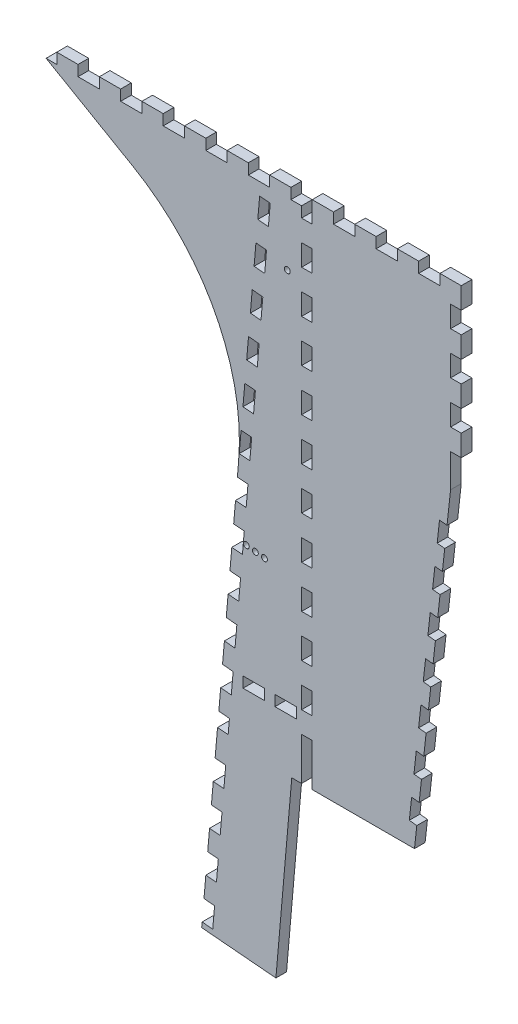
from build123d import *

# Parameters (mm, degrees)
SKETCH1_R           = 1.75
BOSS_EXTRUDE1_DEPTH = 6.35
CUT_EXTRUDE1_DEPTH  = 7.35
SKETCH5_W           = 12.7
SKETCH5_H           = 6.35
CUT_EXTRUDE3_DEPTH  = 7.35
FILLET1_R           = 127
LPATTERN1_COUNT     = 10
LPATTERN1_PITCH     = 25.4
SKETCH6_W           = 6.35
SKETCH6_H           = 12.7
CUT_EXTRUDE4_DEPTH  = 7.35
CUT_EXTRUDE5_DEPTH  = 7.35
LPATTERN3_COUNT     = 7
LPATTERN3_PITCH     = 25.4
SKETCH10_W          = 6.35
SKETCH10_H          = 83.214016323
BOSS_EXTRUDE2_DEPTH = 6.35
LPATTERN4_COUNT     = 4
LPATTERN4_PITCH     = 25.4
SKETCH11_W          = 6.35
SKETCH11_H          = 7.014016323
CUT_EXTRUDE7_DEPTH  = 7.35
SKETCH12_W          = 6.35
SKETCH12_H          = 12.7
CUT_EXTRUDE8_DEPTH  = 7.35
LPATTERN5_COUNT     = 12
LPATTERN5_PITCH     = 25.4
CUT_EXTRUDE9_DEPTH  = 7.35
LPATTERN6_COUNT     = 12
LPATTERN6_PITCH     = 25.4
SKETCH15_W          = 12.7
SKETCH15_H          = 6.35
CUT_EXTRUDE10_DEPTH = 7.35
SKETCH16_W          = 6.35
SKETCH16_H          = 12.7
CUT_EXTRUDE11_DEPTH = 7.35
BOSS_EXTRUDE4_DEPTH = 6.35
LPATTERN7_COUNT     = 5
LPATTERN7_PITCH     = 25.4


with BuildPart() as part:
    # Sketch1 → Boss-Extrude1 (new body)
    with BuildSketch(Plane.XY):
        Polygon((-101.927346492, 304.8), (-101.927346492, 298.45), (19.954542011, 228.081458863), (0, 0), (145.722653508, 0), (145.722653508, 304.8), align=None)
        with Locations((17.516544975, 106.665925891)):
            Circle(SKETCH1_R, mode=Mode.SUBTRACT)
        with Locations((22.915962626, 105.907087227)):
            Circle(SKETCH1_R, mode=Mode.SUBTRACT)
        with Locations((28.338574185, 105.337147786)):
            Circle(SKETCH1_R, mode=Mode.SUBTRACT)
        with Locations((41.953172759, 260.952721575)):
            Circle(SKETCH1_R, mode=Mode.SUBTRACT)
    extrude(amount=BOSS_EXTRUDE1_DEPTH)

    # Sketch2 → Cut-Extrude1 (cut, through all)
    with BuildSketch(Plane.XY.offset(6.35)):
        Polygon((145.722653508, 254), (117.824574416, 0), (145.722653508, 0), align=None)
    extrude(amount=-CUT_EXTRUDE1_DEPTH, mode=Mode.SUBTRACT)

    # Sketch5 → Cut-Extrude3 (cut, through all)
    with BuildSketch(Plane.XY.offset(6.35)):
        with Locations((126.672653508, 301.625)):
            Rectangle(SKETCH5_W, SKETCH5_H)
    cut_extrude3 = extrude(amount=-CUT_EXTRUDE3_DEPTH, mode=Mode.SUBTRACT)

    # Fillet1
    fillet1_edges = [part.edges().sort_by_distance(p)[0] for p in [
        (19.954542011, 228.081458863, 3.175),
    ]]
    fillet(fillet1_edges, radius=FILLET1_R)

    # LPattern1: Cut-Extrude3 ×10
    with Locations(*[(-i * LPATTERN1_PITCH, 0, 0) for i in range(1, LPATTERN1_COUNT)]):
        add(cut_extrude3, mode=Mode.SUBTRACT)

    # Sketch6 → Cut-Extrude4 (cut, through all)
    with BuildSketch(Plane.XY.offset(6.35)):
        with Locations((142.547653508, 285.75)):
            Rectangle(SKETCH6_W, SKETCH6_H)
    cut_extrude4 = extrude(amount=-CUT_EXTRUDE4_DEPTH, mode=Mode.SUBTRACT)

    # Sketch8 → Cut-Extrude5 (cut, through all)
    with BuildSketch(Plane.XY.offset(6.35)):
        Polygon((119.211139876, 12.624081599), (120.597705336, 25.248163198), (116.121058229, 25.739855541), (114.734492769, 13.115773942), align=None)
    cut_extrude5 = extrude(amount=-CUT_EXTRUDE5_DEPTH, mode=Mode.SUBTRACT)

    # LPattern3: Cut-Extrude5 ×7
    with Locations(*[Vector(0.109178383, 0.994022173, 0) * (i * LPATTERN3_PITCH) for i in range(1, LPATTERN3_COUNT)]):
        add(cut_extrude5, mode=Mode.SUBTRACT)

    # Sketch10 → Boss-Extrude2 (add, through all)
    with BuildSketch(Plane.XY.offset(6.35)):
        with Locations((142.547653508, 237.792991839)):
            Rectangle(SKETCH10_W, SKETCH10_H)
    extrude(amount=-BOSS_EXTRUDE2_DEPTH)

    # LPattern4: Cut-Extrude4 ×4
    with Locations(*[(0, -i * LPATTERN4_PITCH, 0) for i in range(1, LPATTERN4_COUNT)]):
        add(cut_extrude4, mode=Mode.SUBTRACT)

    # Sketch11 → Cut-Extrude7 (cut, through all)
    with BuildSketch(Plane.XY.offset(6.35)):
        with Locations((142.547653508, 199.692991839)):
            Rectangle(SKETCH11_W, SKETCH11_H)
    extrude(amount=-CUT_EXTRUDE7_DEPTH, mode=Mode.SUBTRACT)

    # Sketch12 → Cut-Extrude8 (cut, through all)
    with BuildSketch(Plane.XY.offset(6.35)):
        with Locations((53.647653508, 19.05)):
            Rectangle(SKETCH12_W, SKETCH12_H)
    cut_extrude8 = extrude(amount=-CUT_EXTRUDE8_DEPTH, mode=Mode.SUBTRACT)

    # LPattern5: Cut-Extrude8 ×12
    with Locations(*[(0, i * LPATTERN5_PITCH, 0) for i in range(1, LPATTERN5_COUNT)]):
        add(cut_extrude8, mode=Mode.SUBTRACT)

    # Sketch13 → Cut-Extrude9 (cut, through all)
    with BuildSketch(Plane.XY.offset(6.35)):
        Polygon((0, 0), (1.106877933, 12.651672666), (7.432714266, 12.098233699), (6.325836333, -0.553438966), align=None)
    cut_extrude9 = extrude(amount=-CUT_EXTRUDE9_DEPTH, mode=Mode.SUBTRACT)

    # LPattern6: Cut-Extrude9 ×12
    with Locations(*[Vector(0.087155743, 0.996194698, 0) * (i * LPATTERN6_PITCH) for i in range(1, LPATTERN6_COUNT)]):
        add(cut_extrude9, mode=Mode.SUBTRACT)

    # Sketch15 → Cut-Extrude10 (cut, through all)
    with BuildSketch(Plane.XY.offset(6.35)):
        with Locations((40.947653508, 34.925)):
            Rectangle(SKETCH15_W, SKETCH15_H)
        with Locations((21.897653508, 34.925)):
            Rectangle(SKETCH15_W, SKETCH15_H)
    extrude(amount=-CUT_EXTRUDE10_DEPTH, mode=Mode.SUBTRACT)

    # Sketch16 → Cut-Extrude11 (cut, through all)
    with BuildSketch(Plane.XY.offset(6.35)):
        with Locations((53.647653508, 6.35)):
            Rectangle(SKETCH16_W, SKETCH16_H)
    extrude(amount=-CUT_EXTRUDE11_DEPTH, mode=Mode.SUBTRACT)

    # Sketch20 → Boss-Extrude4 (add)
    with BuildSketch(Plane.XY.offset(6.35)):
        Polygon((0.338937449, 3.874072765), (44.619791779, 0), (35.157058037, -108.159541598), (-9.123796293, -104.285468833), align=None)
    extrude(amount=-BOSS_EXTRUDE4_DEPTH)

    # LPattern7: Cut-Extrude9 ×5
    with Locations(*[Vector(-0.087155743, -0.996194698, 0) * (i * LPATTERN7_PITCH) for i in range(1, LPATTERN7_COUNT)]):
        add(cut_extrude9, mode=Mode.SUBTRACT)


solid = part.part
